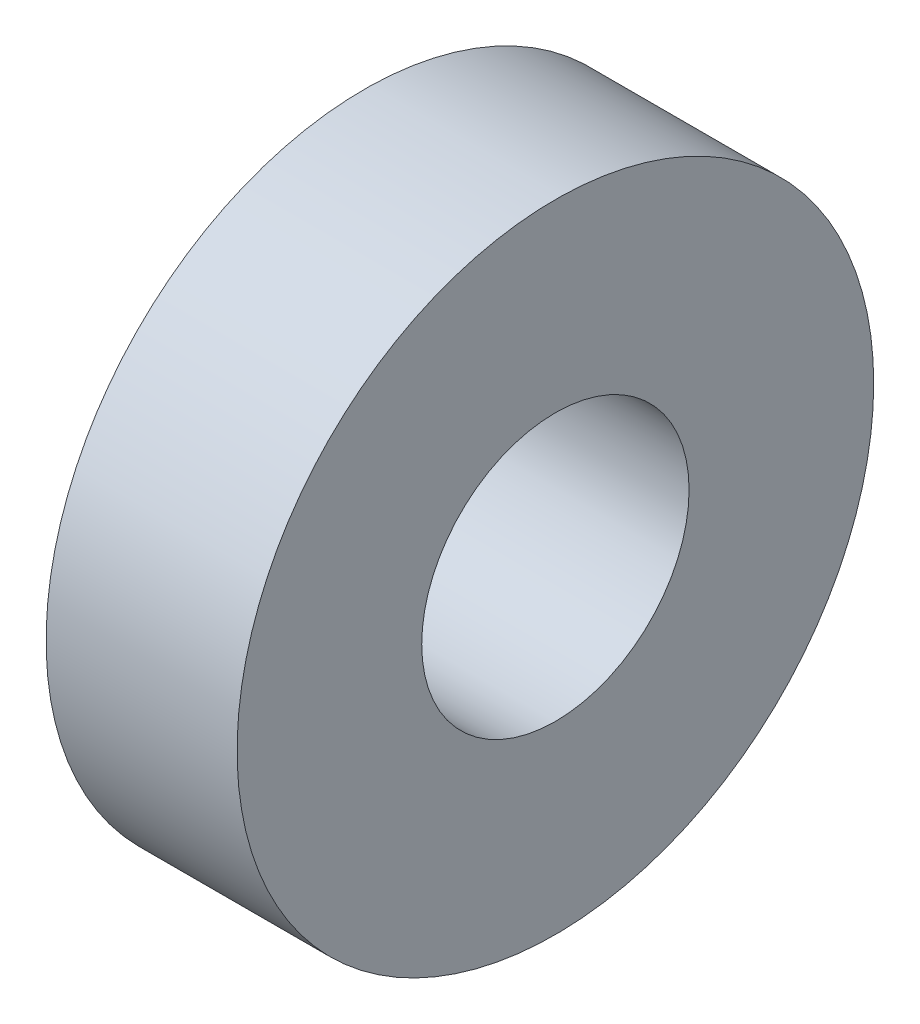
from build123d import *

# Parameters (mm, degrees)
ESQUISSE1_R      = 5
ESQUISSE1_R_2    = 2.1
EXTRUSION1_DEPTH = 3


with BuildPart() as part:
    # Esquisse1 → Extrusion1 (new body)
    with BuildSketch(Plane(origin=(0, 0, 0), x_dir=(0, 0, -1), z_dir=(1, 0, 0))):
        Circle(ESQUISSE1_R)
        Circle(ESQUISSE1_R_2, mode=Mode.SUBTRACT)
    extrude(amount=EXTRUSION1_DEPTH)


solid = part.part
